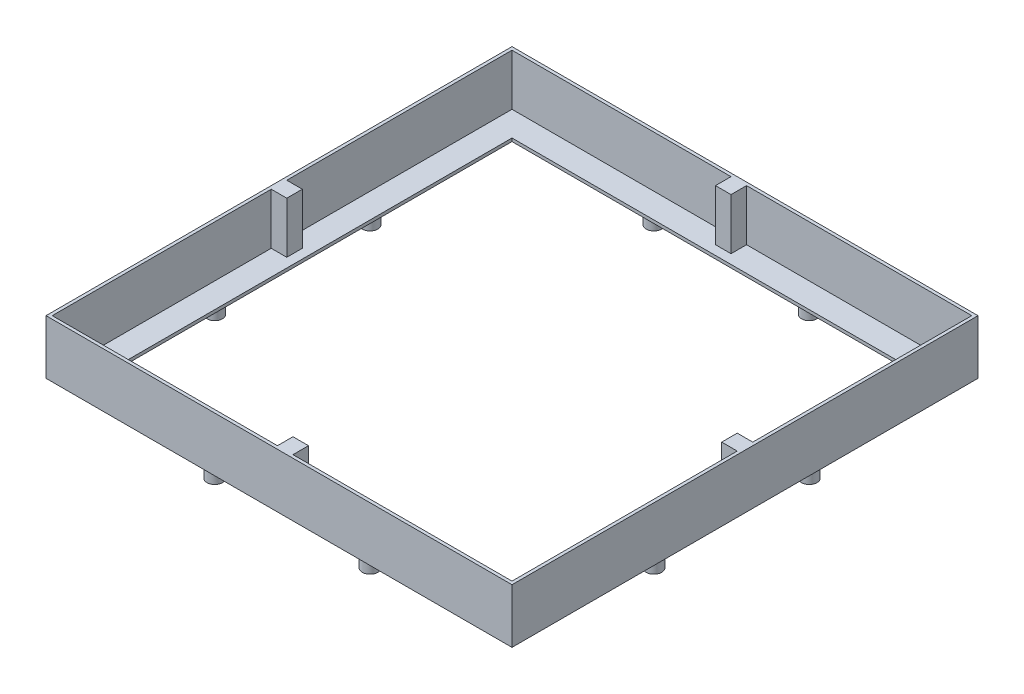
from build123d import *

# Parameters (mm, degrees)
SKETCH1_W           = 150
SKETCH1_H           = 150
BOSS_EXTRUDE1_DEPTH = 17.48
SKETCH2_W           = 148
SKETCH2_H           = 148
CUT_EXTRUDE1_DEPTH  = 16.48
SKETCH3_W           = 132
SKETCH3_H           = 132
CUT_EXTRUDE2_DEPTH  = 108.338671503
SKETCH4_W           = 5
SKETCH4_H           = 17.47
BOSS_EXTRUDE3_DEPTH = 5
CIRPATTERN2_COUNT   = 4
SKETCH6_R           = 2.5
BOSS_EXTRUDE5_DEPTH = 5


with BuildPart() as part:
    # Sketch1 → Boss-Extrude1 (new body)
    with BuildSketch(Plane(origin=(0, 0, 0), x_dir=(1, 0, 0), z_dir=(0, 1, 0))):
        Rectangle(SKETCH1_W, SKETCH1_H)
    extrude(amount=-BOSS_EXTRUDE1_DEPTH)

    # Sketch2 → Cut-Extrude1 (cut)
    with BuildSketch(Plane(origin=(0, 0, 0), x_dir=(1, 0, 0), z_dir=(0, 1, 0))):
        Rectangle(SKETCH2_W, SKETCH2_H)
    extrude(amount=-CUT_EXTRUDE1_DEPTH, mode=Mode.SUBTRACT)

    # Sketch3 → Cut-Extrude2 (cut, through all)
    with BuildSketch(Plane(origin=(0, -16.48, 0), x_dir=(1, 0, 0), z_dir=(0, 1, 0))):
        Rectangle(SKETCH3_W, SKETCH3_H)
    extrude(amount=-CUT_EXTRUDE2_DEPTH, mode=Mode.SUBTRACT)

    # Sketch4 → Boss-Extrude3 (add)
    with BuildSketch(Plane.XY.offset(-74)):
        with Locations((-1, -8.735)):
            Rectangle(SKETCH4_W, SKETCH4_H)
    boss_extrude3 = extrude(amount=BOSS_EXTRUDE3_DEPTH)

    # CirPattern2: Boss-Extrude3 ×4 about axis
    cirpattern2_axis = Axis((0, 0, 0), (0, 1, 0))
    for i in range(1, CIRPATTERN2_COUNT):
        add(boss_extrude3.rotate(cirpattern2_axis, i * 360 / CIRPATTERN2_COUNT))

    # Sketch6 → Boss-Extrude5 (add)
    with BuildSketch(Plane.XZ.offset(17.48)):
        with Locations((-70.678187872, -25)):
            Circle(SKETCH6_R)
        with Locations((-70.678187872, 25)):
            Circle(SKETCH6_R)
        with Locations((25, 70.678187872)):
            Circle(SKETCH6_R)
        with Locations((-25, 70.678187872)):
            Circle(SKETCH6_R)
        with Locations((70.678187872, -25)):
            Circle(SKETCH6_R)
        with Locations((70.678187872, 25)):
            Circle(SKETCH6_R)
        with Locations((-25, -70.678187872)):
            Circle(SKETCH6_R)
        with Locations((25, -70.678187872)):
            Circle(SKETCH6_R)
    extrude(amount=BOSS_EXTRUDE5_DEPTH)


solid = part.part
